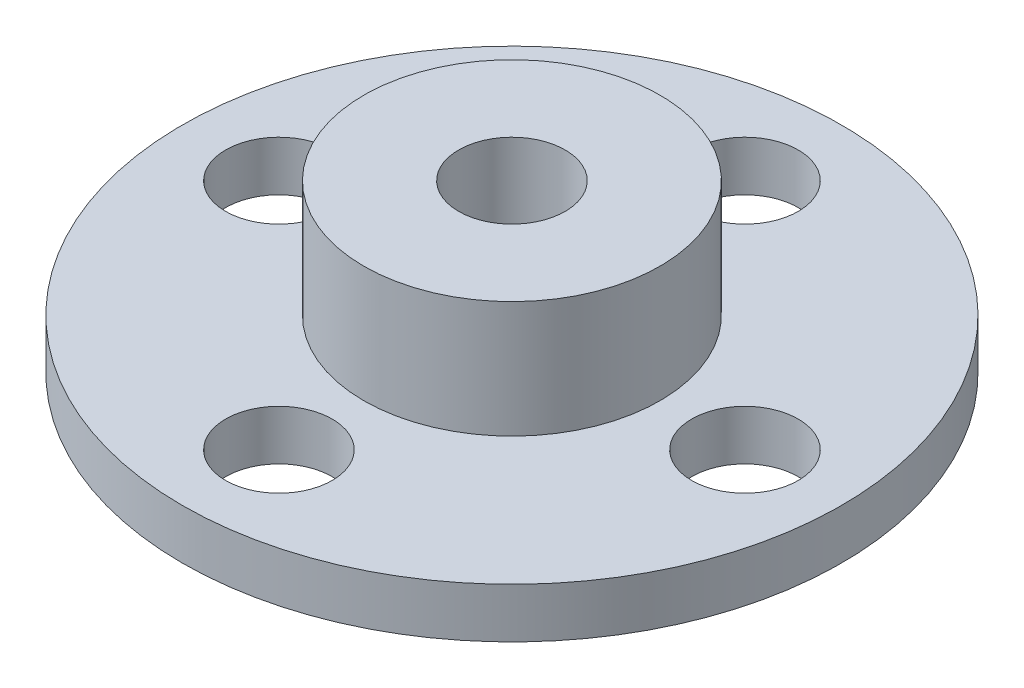
from build123d import *

# Parameters (mm, degrees)
SKETCH1_R           = 9.9
SKETCH1_R_2         = 1.6
BOSS_EXTRUDE1_DEPTH = 1.5
SKETCH2_R           = 4.45
SKETCH2_R_2         = 1.6
BOSS_EXTRUDE3_DEPTH = 3.5


with BuildPart() as part:
    # Sketch1 → Boss-Extrude1 (new body)
    with BuildSketch(Plane(origin=(0, 0, 0), x_dir=(1, 0, 0), z_dir=(0, 1, 0))):
        Circle(SKETCH1_R)
        Circle(SKETCH1_R_2, mode=Mode.SUBTRACT)
        with Locations((0, 7)):
            Circle(SKETCH1_R_2, mode=Mode.SUBTRACT)
        with Locations((7, 0)):
            Circle(SKETCH1_R_2, mode=Mode.SUBTRACT)
        with Locations((0, -7)):
            Circle(SKETCH1_R_2, mode=Mode.SUBTRACT)
        with Locations((-7, 0)):
            Circle(SKETCH1_R_2, mode=Mode.SUBTRACT)
    extrude(amount=BOSS_EXTRUDE1_DEPTH)

    # Sketch2 → Boss-Extrude3 (add)
    with BuildSketch(Plane(origin=(0, 1.5, 0), x_dir=(1, 0, 0), z_dir=(0, 1, 0))):
        Circle(SKETCH2_R)
        Circle(SKETCH2_R_2, mode=Mode.SUBTRACT)
    extrude(amount=BOSS_EXTRUDE3_DEPTH)


solid = part.part
